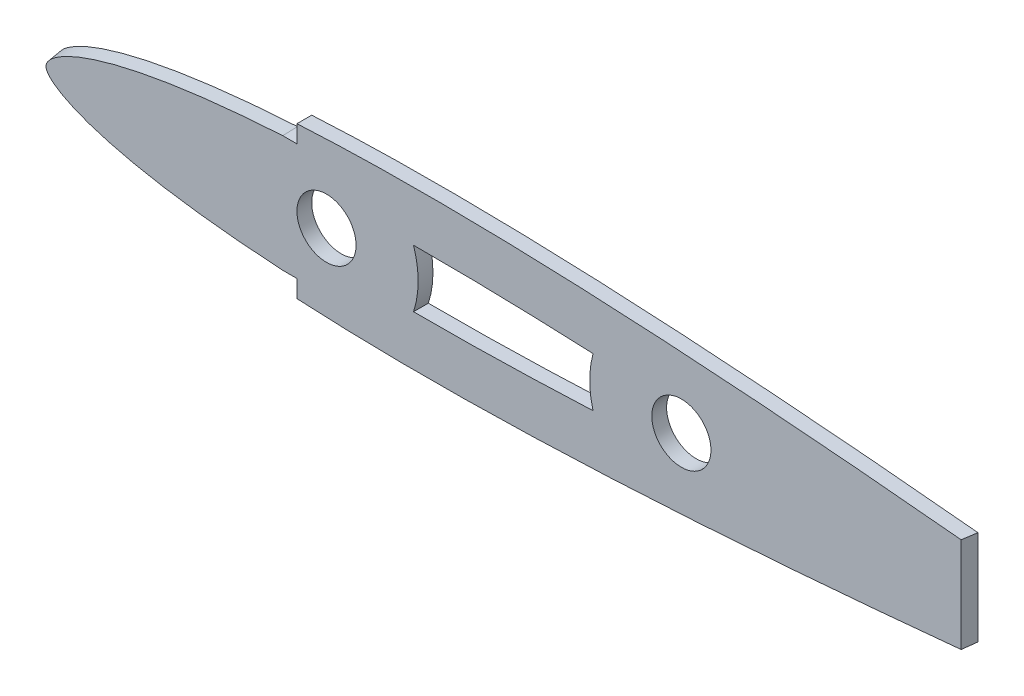
from build123d import *

# Parameters (mm, degrees)
BOSS_EXTRUDE1_DEPTH     = 3.175
SKETCH2_R               = 6.35
CUT_EXTRUDE1_DEPTH      = 3.175
CUT_EXTRUDE2_DEPTH      = 17.98531302
CUT_EXTRUDE2_DEPTH_BACK = 17.98531302
CUT_EXTRUDE3_DEPTH      = 7.62


with BuildPart() as part:
    # Sketch1 → Boss-Extrude1 (new body)
    with BuildSketch(Plane.XY):
        with BuildLine():
            add(Edge.make_bspline(
                [(283.0068, 0.356588568), (282.901747419, 0.44462405), (282.222988768, 0.361501496), (281.014292834, 0.701750535), (278.797705315, 0.912055534), (275.811625252, 1.363395917), (271.96510687, 1.867061556), (267.326448481, 2.487806401), (261.907718596, 3.189499382), (255.748156548, 3.970743632), (248.883761402, 4.817852882), (241.357474346, 5.719362844), (233.215556988, 6.664092103), (224.508147533, 7.639178426), (215.288960535, 8.632716794), (205.614900546, 9.632367333), (195.545587828, 10.625227013), (185.143130495, 11.597359066), (174.471591387, 12.536001404), (163.596880752, 13.425461607), (152.585818931, 14.251236992), (141.506392817, 14.997996378), (130.426867175, 15.650125673), (119.415450083, 16.19114965), (108.540147703, 16.606641404), (97.867696152, 16.883046032), (87.464049003, 17.006862886), (77.393132365, 16.968265808), (67.717036062, 16.75979946), (58.495320886, 16.376179449), (49.784748261, 15.816402284), (41.638853683, 15.082152298), (34.107484228, 14.179164014), (27.236546007, 13.115120527), (21.067675242, 11.901134861), (15.637028536, 10.550933877), (10.975465177, 9.077683717), (7.106668967, 7.49510566), (4.042977604, 5.813906592), (1.789105378, 4.030768344), (0.345518556, 2.10255275), (-0.161023932, 0), (0.345518556, -2.10255275), (1.789105378, -4.030768344), (4.042977604, -5.813906592), (7.106668967, -7.49510566), (10.975465177, -9.077683717), (15.637028536, -10.550933877), (21.067675242, -11.901134861), (27.236546007, -13.115120527), (34.107484228, -14.179164014), (41.638853683, -15.082152298), (49.784748261, -15.816402284), (58.495320886, -16.376179449), (67.717036062, -16.75979946), (77.393132365, -16.968265808), (87.464049003, -17.006862886), (97.867696152, -16.883046032), (108.540147703, -16.606641404), (119.415450083, -16.19114965), (130.426867175, -15.650125673), (141.506392817, -14.997996378), (152.585818931, -14.251236992), (163.596880752, -13.425461607), (174.471591387, -12.536001404), (185.143130495, -11.597359066), (195.545587828, -10.625227013), (205.614900546, -9.632367333), (215.288960535, -8.632716794), (224.508147533, -7.639178426), (233.215556988, -6.664092103), (241.357474346, -5.719362844), (248.883761402, -4.817852882), (255.748156548, -3.970743632), (261.907718596, -3.189499382), (267.326448481, -2.487806401), (271.96510687, -1.867061556), (275.811625252, -1.363395917), (278.797705315, -0.912055534), (281.014292834, -0.701750535), (282.222988768, -0.361501496), (283.176929529, -0.478323569), (283.176929529, 0.214017725), (283.0068, 0.356588568)],
                knots=[0, 0, 0, 0, 0.000762215, 0.003044706, 0.006832246, 0.012101176, 0.018817536, 0.026939455, 0.036414848, 0.047184628, 0.059180413, 0.072327874, 0.086544061, 0.10174058, 0.117823336, 0.134691452, 0.152240154, 0.17036129, 0.188941008, 0.207865435, 0.227016078, 0.246275696, 0.265524943, 0.284644966, 0.303520118, 0.322034575, 0.340078353, 0.357542593, 0.374325482, 0.390329891, 0.40546389, 0.419643801, 0.432793371, 0.444843817, 0.455737921, 0.465428653, 0.47388632, 0.481101634, 0.487101684, 0.491975368, 0.495930678, 0.499382808, 0.502834938, 0.506790248, 0.511663932, 0.517663982, 0.524879296, 0.533336963, 0.543027695, 0.553921799, 0.565972245, 0.579121815, 0.593301726, 0.608435725, 0.624440134, 0.641223023, 0.658687263, 0.676731041, 0.695245498, 0.71412065, 0.733240673, 0.75248992, 0.771749538, 0.790900181, 0.809824608, 0.828404326, 0.846525462, 0.864074164, 0.88094228, 0.897025036, 0.912221555, 0.926437743, 0.939585203, 0.951580988, 0.962350768, 0.971826162, 0.979948081, 0.986664441, 0.991933371, 0.99572091, 0.998003402, 0.998765616, 1, 1, 1, 1], degree=3))
        make_face()
    extrude(amount=BOSS_EXTRUDE1_DEPTH)

    # Sketch2 → Cut-Extrude1 (cut)
    with BuildSketch(Plane.XY.offset(3.175)):
        with Locations((63.5, 0)):
            Circle(SKETCH2_R)
        with Locations((139.7, 0)):
            Circle(SKETCH2_R)
    extrude(amount=-CUT_EXTRUDE1_DEPTH, mode=Mode.SUBTRACT)

    # Sketch3 → Cut-Extrude2 (cut, two sides)
    with BuildSketch(Plane(origin=(0, 0, 0), x_dir=(1, 0, 0), z_dir=(0, 1, 0))) as cut_extrude2_sk:
        Polygon((280.502264678, 570.685147201), (200.220132014, 0), (199.773483328, -3.175), (283.134397147, -3.175), (283.134397147, 0), (283.134397147, 576.304397051), (-760.640477334, 1065.222635252), (-763.272609802, 1059.603385401), align=None)
    extrude(amount=CUT_EXTRUDE2_DEPTH, mode=Mode.SUBTRACT)
    extrude(cut_extrude2_sk.sketch, amount=-CUT_EXTRUDE2_DEPTH_BACK, mode=Mode.SUBTRACT)

    # Sketch5 → Cut-Loft1 section 0
    with BuildSketch(Plane.XY.offset(3.175)):
        with BuildLine():
            Line((57.15, -15.840717611), (57.15, -12.517848774))
            Line((57.15, -12.517848774), (54.102, -12.517848774))
            add(Edge.make_bspline(
                [(54.102, 12.517848774), (52.905073826, 12.446922239), (50.510877245, 12.29292233), (46.923042309, 12.02249839), (43.342906141, 11.709637993), (39.772343425, 11.350207554), (36.212958119, 10.940125109), (32.668672918, 10.473083309), (29.140579279, 9.942416236), (26.221744689, 9.439792705), (23.899631399, 8.996334016), (22.168124881, 8.641223297), (20.447130555, 8.261260302), (18.73921392, 7.85440932), (17.04583843, 7.418483842), (15.37131979, 6.950314461), (13.720374707, 6.446953018), (12.099093951, 5.903590986), (10.516736009, 5.316840777), (8.982942702, 4.676356823), (7.515425701, 3.975597981), (6.148367378, 3.214391725), (5.132435214, 2.525362189), (4.436328841, 1.942644965), (3.99449908, 1.50088383), (3.639558845, 1.055711416), (3.418173473, 0.67028204), (3.294529971, 0.303832168), (3.258254336, 8.98e-07), (3.294531501, -0.303834398), (3.41817022, -0.670279004), (3.63956519, -1.05571658), (3.994486701, -1.500874192), (4.436322379, -1.942640233), (5.13276687, -2.525613649), (6.148175252, -3.21424607), (7.515525046, -3.97567324), (8.982885795, -4.676313816), (10.516775422, -5.316870372), (12.099068229, -5.90357211), (13.720394844, -6.446967156), (15.371289631, -6.95029465), (17.045828606, -7.418477981), (18.739219111, -7.854412516), (20.44713727, -8.261264475), (22.168119663, -8.641219802), (23.899622625, -8.996332253), (26.221845214, -9.439810116), (29.140506404, -9.942404258), (32.668709943, -10.473088914), (36.212941173, -10.940123046), (39.772346311, -11.350206942), (43.342914131, -11.709640819), (46.923012021, -12.0224901), (50.510859023, -12.292917903), (52.905073826, -12.446922239), (54.102, -12.517848774)],
                knots=[0, 0, 0, 0, 0.03125, 0.0625, 0.09375, 0.125, 0.15625, 0.1875, 0.21875, 0.25, 0.265625, 0.28125, 0.296875, 0.3125, 0.328125, 0.34375, 0.359375, 0.375, 0.390625, 0.40625, 0.421875, 0.4375, 0.453125, 0.4609375, 0.46875, 0.4765625, 0.484375, 0.4921875, 0.5, 0.5078125, 0.515625, 0.5234375, 0.53125, 0.5390625, 0.546875, 0.5625, 0.578125, 0.59375, 0.609375, 0.625, 0.640625, 0.65625, 0.671875, 0.6875, 0.703125, 0.71875, 0.734375, 0.75, 0.78125, 0.8125, 0.84375, 0.875, 0.90625, 0.9375, 0.96875, 1, 1, 1, 1], degree=3))
            Line((54.102, 12.517848774), (57.15, 12.517848774))
            Line((57.15, 12.517848774), (57.15, 15.840717611))
            Line((57.15, 15.840717611), (57.15, 24.528656823))
            Line((57.15, 24.528656823), (-13.660315185, 32.196838039))
            Line((-13.660315185, 32.196838039), (4.751362513, -35.926369443))
            Line((4.751362513, -35.926369443), (57.15, -29.012871964))
            Line((57.15, -29.012871964), (57.15, -15.840717611))
        make_face()
    # Sketch4 → Cut-Loft1 section 1
    with BuildSketch(Plane(origin=(0, 0, 0), x_dir=(-1, 0, 0), z_dir=(0, 0, -1))):
        with BuildLine():
            Line((-57.15, -15.931097341), (-57.15, -12.614401813))
            Line((-57.15, -12.614401813), (-54.102, -12.614401813))
            add(Edge.make_bspline(
                [(-54.102, 12.614401813), (-52.892966304, 12.543650374), (-50.474562395, 12.389900929), (-46.850429349, 12.119518431), (-43.233994008, 11.80632974), (-39.627106768, 11.446155851), (-36.031309682, 11.034861155), (-32.450571185, 10.566087473), (-28.885974607, 10.033109549), (-25.936699002, 9.527992325), (-23.590171059, 9.082138578), (-21.840349809, 8.725010585), (-20.101018277, 8.342781179), (-18.374759552, 7.933393598), (-16.663038707, 7.494638099), (-14.970151675, 7.023265253), (-13.3008012, 6.516250081), (-11.661107617, 5.968693544), (-10.06037111, 5.377118947), (-8.508330893, 4.731019213), (-7.022897298, 4.023737888), (-5.63853584, 3.25470078), (-4.609088563, 2.55765795), (-3.903506054, 1.967798123), (-3.455598612, 1.52050909), (-3.095749955, 1.069692125), (-2.871302388, 0.679325256), (-2.745924545, 0.30796261), (-2.7091298, 9.1e-07), (-2.745926097, -0.307964873), (-2.871299087, -0.679322175), (-3.095756394, -1.069697364), (-3.455586055, -1.520499314), (-3.903499495, -1.967793321), (-4.609425021, -2.557913052), (-5.638340949, -3.254553026), (-7.022998045, -4.023814214), (-8.50827323, -4.730975626), (-10.060410962, -5.377148887), (-11.661081805, -5.968674575), (-13.300821123, -6.516264103), (-14.970122445, -7.02324602), (-16.6630295, -7.494632633), (-18.374764393, -7.933396571), (-20.10102481, -8.342785237), (-21.840344745, -8.725007186), (-23.590162295, -9.082136874), (-25.936800786, -9.528009858), (-28.88590077, -10.033097475), (-32.450608778, -10.56609314), (-36.031292313, -11.034859029), (-39.627110143, -11.446155342), (-43.234001329, -11.806332406), (-46.850400529, -12.119510514), (-50.474544843, -12.389896679), (-52.892966304, -12.543650374), (-54.102, -12.614401813)],
                knots=[0, 0, 0, 0, 0.03125, 0.0625, 0.09375, 0.125, 0.15625, 0.1875, 0.21875, 0.25, 0.265625, 0.28125, 0.296875, 0.3125, 0.328125, 0.34375, 0.359375, 0.375, 0.390625, 0.40625, 0.421875, 0.4375, 0.453125, 0.4609375, 0.46875, 0.4765625, 0.484375, 0.4921875, 0.5, 0.5078125, 0.515625, 0.5234375, 0.53125, 0.5390625, 0.546875, 0.5625, 0.578125, 0.59375, 0.609375, 0.625, 0.640625, 0.65625, 0.671875, 0.6875, 0.703125, 0.71875, 0.734375, 0.75, 0.78125, 0.8125, 0.84375, 0.875, 0.90625, 0.9375, 0.96875, 1, 1, 1, 1], degree=3))
            Line((-54.102, 12.614401813), (-57.15, 12.614401813))
            Line((-57.15, 12.614401813), (-57.15, 15.931097341))
            Line((-57.15, 15.931097341), (-57.15, 23.768946795))
            Line((-57.15, 23.768946795), (16.290986713, 29.461293478))
            Line((16.290986713, 29.461293478), (3.107394198, -36.097931887))
            Line((3.107394198, -36.097931887), (-57.15, -26.910981695))
            Line((-57.15, -26.910981695), (-57.15, -15.931097341))
        make_face()
    loft(mode=Mode.SUBTRACT)

    # Sketch6 → Cut-Extrude3 (cut)
    with BuildSketch(Plane(origin=(0, 0, 0), x_dir=(-1, 0, 0), z_dir=(0, 0, -1))):
        with BuildLine():
            ThreePointArc((-120.7436607, -5.30626284), (-120.015, 0), (-120.7436607, 5.30626284))
            add(Edge.make_bspline(
                [(-120.7436607, 5.30626284), (-116.113978677, 5.516834405), (-111.486849996, 5.695579464), (-101.374008891, 6.004242594), (-95.890716435, 6.118585943), (-87.671447186, 6.189682577), (-84.92815734, 6.19667575), (-82.188251061, 6.184536948)],
                knots=[0.519741838, 0.519741838, 0.519741838, 0.519741838, 0.625, 0.625, 0.75, 0.75, 0.812699407, 0.812699407, 0.812699407, 0.812699407], degree=3))
            ThreePointArc((-82.188251061, 6.184536948), (-83.185, 0), (-82.188251061, -6.184536948))
            add(Edge.make_bspline(
                [(-82.188251061, -6.184536948), (-84.92815734, -6.19667575), (-87.671447186, -6.189682577), (-95.890716436, -6.118585943), (-101.374008891, -6.004242594), (-111.486849996, -5.695579464), (-116.113978677, -5.516834405), (-120.7436607, -5.30626284)],
                knots=[0.187300593, 0.187300593, 0.187300593, 0.187300593, 0.25, 0.25, 0.375, 0.375, 0.480258162, 0.480258162, 0.480258162, 0.480258162], degree=3))
        make_face()
    extrude(amount=-CUT_EXTRUDE3_DEPTH, mode=Mode.SUBTRACT)


solid = part.part
